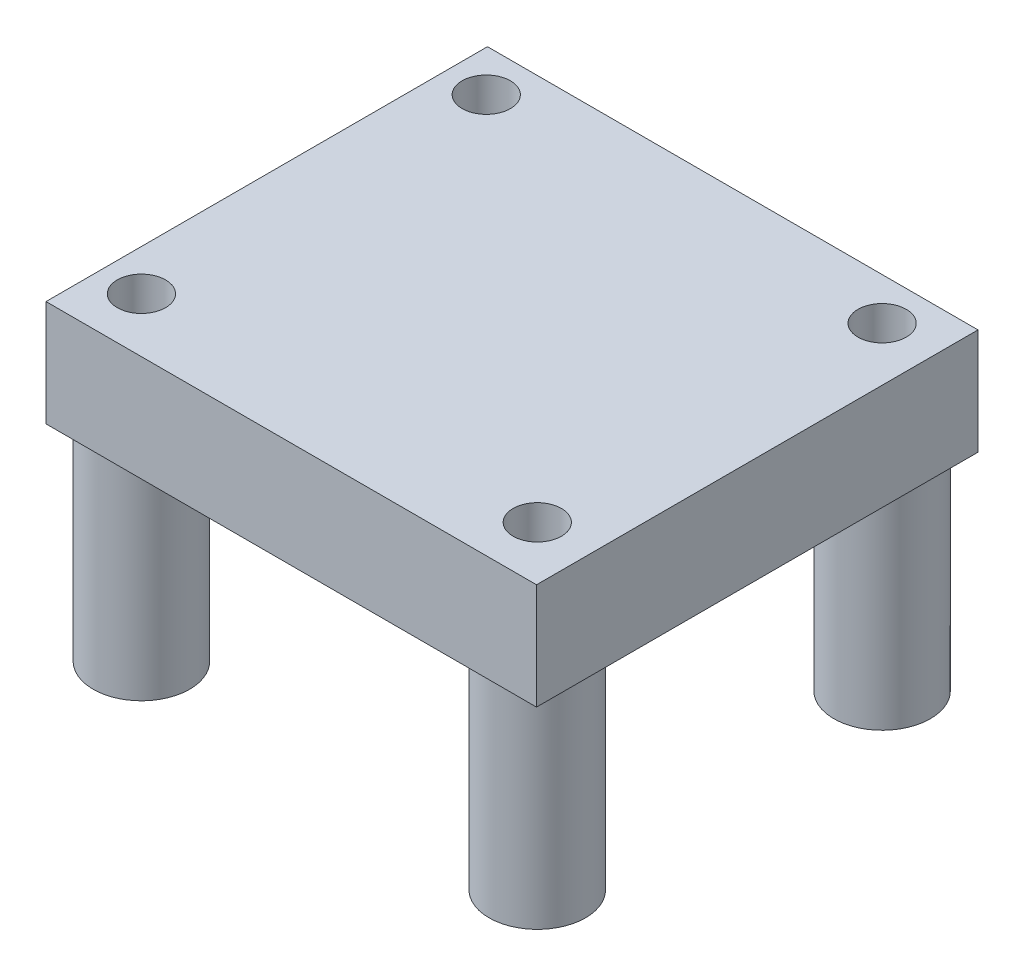
from build123d import *

# Parameters (mm, degrees)
SKETCH1_W               = 25.4
SKETCH1_H               = 22.86
BOSS_EXTRUDE1_DEPTH     = 5.4864
SKETCH2_R               = 2.5
SKETCH2_R_2             = 1.25
BOSS_EXTRUDE2_DEPTH     = 11
SKETCH5_R               = 1.25
CUT_EXTRUDE1_DEPTH      = 1
CUT_EXTRUDE1_DEPTH_BACK = 17.4864


with BuildPart() as part:
    # Sketch1 → Boss-Extrude1 (new body)
    with BuildSketch(Plane(origin=(0, 0, 0), x_dir=(1, 0, 0), z_dir=(0, 1, 0))):
        with Locations((-21.340699551, -9.756889686)):
            Rectangle(SKETCH1_W, SKETCH1_H)
    extrude(amount=BOSS_EXTRUDE1_DEPTH)

    # Sketch2 → Boss-Extrude2 (add)
    with BuildSketch(Plane.XZ):
        with Locations((-31.918497565, 18.367860399)):
            Circle(SKETCH2_R)
        with Locations((-31.918497565, 18.367860399)):
            Circle(SKETCH2_R_2, mode=Mode.SUBTRACT)
        with Locations((-31.918497565, 0.511660399)):
            Circle(SKETCH2_R)
        with Locations((-31.918497565, 0.511660399)):
            Circle(SKETCH2_R_2, mode=Mode.SUBTRACT)
        with Locations((-11.420697565, 0.511660399)):
            Circle(SKETCH2_R)
        with Locations((-11.420697565, 0.511660399)):
            Circle(SKETCH2_R_2, mode=Mode.SUBTRACT)
        with Locations((-11.420697565, 18.367860399)):
            Circle(SKETCH2_R)
        with Locations((-11.420697565, 18.367860399)):
            Circle(SKETCH2_R_2, mode=Mode.SUBTRACT)
    extrude(amount=BOSS_EXTRUDE2_DEPTH)

    # Sketch5 → Cut-Extrude1 (cut, two sides)
    with BuildSketch(Plane(origin=(0, 5.4864, 0), x_dir=(1, 0, 0), z_dir=(0, 1, 0))) as cut_extrude1_sk:
        with Locations((-31.918497565, -0.511660399)):
            Circle(SKETCH5_R)
        with Locations((-11.420697565, -0.511660399)):
            Circle(SKETCH5_R)
        with Locations((-11.420697565, -18.367860399)):
            Circle(SKETCH5_R)
        with Locations((-31.918497565, -18.367860399)):
            Circle(SKETCH5_R)
    extrude(amount=CUT_EXTRUDE1_DEPTH, mode=Mode.SUBTRACT)
    extrude(cut_extrude1_sk.sketch, amount=-CUT_EXTRUDE1_DEPTH_BACK, mode=Mode.SUBTRACT)


solid = part.part
